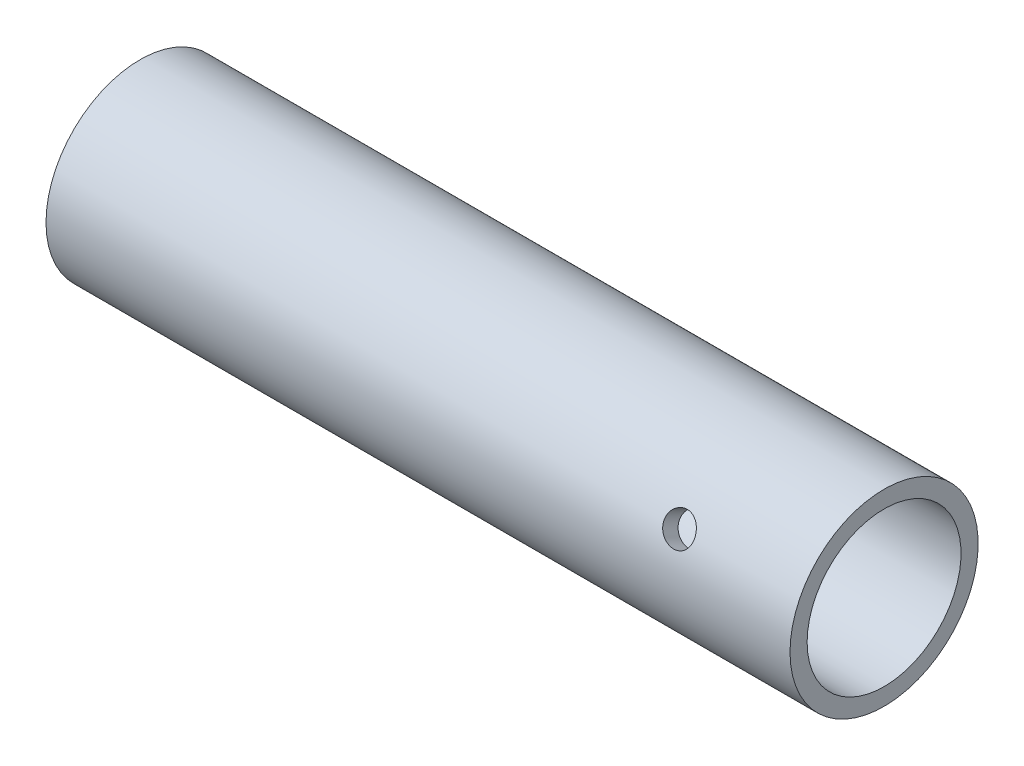
from build123d import *

# Parameters (mm, degrees)
SKETCH4_R          = 0.9
CUT_EXTRUDE1_DEPTH = 336.963729195


with BuildPart() as part:
    # Sketch3 → Revolve19 (revolve)
    with BuildSketch(Plane.XY):
        Polygon((295.058388758, -144.573704322), (295.058388758, -144.073704322), (305.058388758, -144.073704322), (305.058388758, -143.073704322), (261.558388758, -143.073704322), (261.558388758, -144.323704322), (261.558388758, -148.073704322), (263.058388758, -148.073704322), (263.058388758, -144.573704322), align=None)
    revolve(axis=Axis((263.058388758, -148.573704322, 0), (1, 0, 0)))

    # Sketch4 → Cut-Extrude1 (cut, through all)
    with BuildSketch(Plane(origin=(0, -26.447590039, -53.851341485), x_dir=(1, 0, 0), z_dir=(0, 0.4408273328513724, 0.8975919243237127))):
        with Locations((298.024345503, -133.358557166)):
            Circle(SKETCH4_R)
    extrude(amount=-CUT_EXTRUDE1_DEPTH, mode=Mode.SUBTRACT)


solid = part.part
